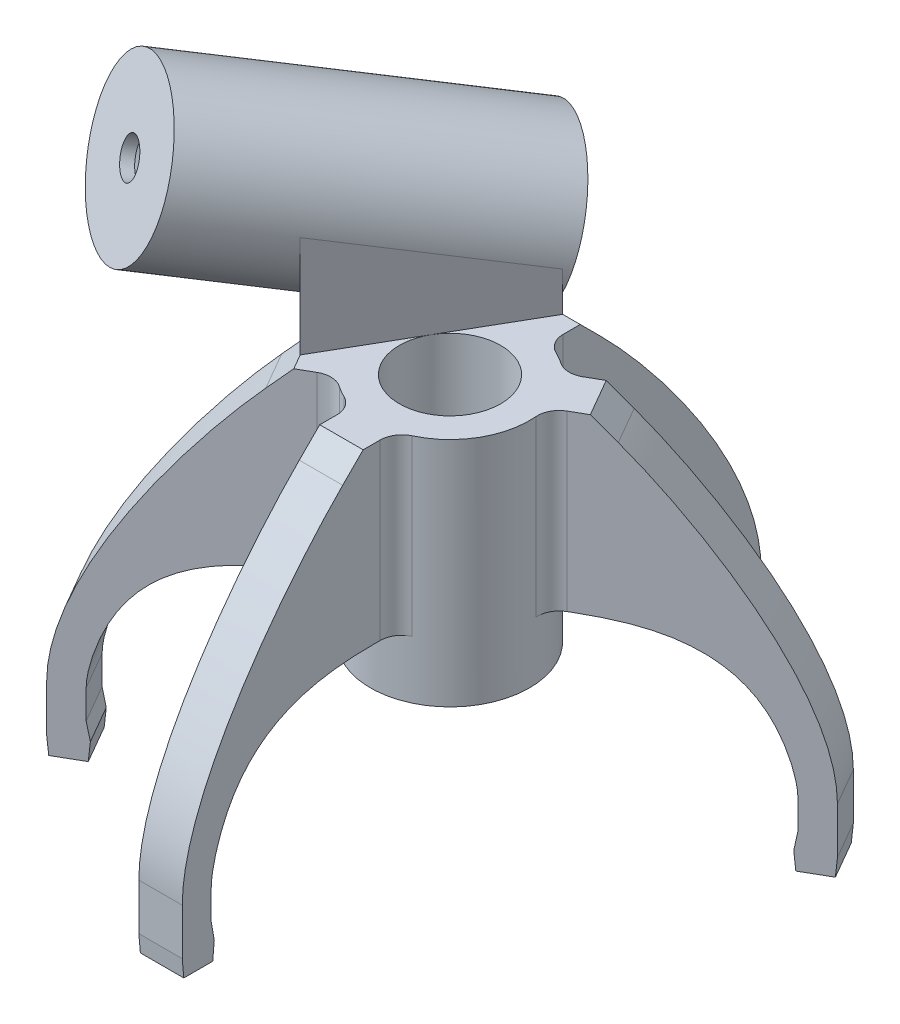
from build123d import *

# Parameters (mm, degrees)
SKETCH1_R                = 5.5
SKETCH1_R_2              = 1.25
BOSS_EXTRUDE1_DEPTH      = 16
BOSS_EXTRUDE2_DEPTH      = 1.5
BOSS_EXTRUDE3_DEPTH      = 3
CIRPATTERN1_COUNT        = 5
CIRPATTERN1_ANGLE        = 240
FILLET1_R                = 1.5
SKETCH6_R                = 3.5
CUT_EXTRUDE1_DEPTH       = 15.2
SKETCH10_R               = 5.5
SKETCH10_R_2             = 1.25
BOSS_EXTRUDE4_DEPTH      = 16
BOSS_EXTRUDE4_DEPTH_BACK = 6
BOSS_EXTRUDE10_REACH     = 16.574
SKETCH11_R               = 3.5
CUT_EXTRUDE2_DEPTH       = 21.2


with BuildPart() as part:
    # Sketch1 → Boss-Extrude1 (new body)
    with BuildSketch(Plane(origin=(0, 0, 0), x_dir=(1, 0, 0), z_dir=(0, 1, 0))):
        Circle(SKETCH1_R)
        Circle(SKETCH1_R_2, mode=Mode.SUBTRACT)
    extrude(amount=BOSS_EXTRUDE1_DEPTH)

    # Sketch2 → Boss-Extrude2 (add, symmetric)
    with BuildSketch(Plane(origin=(0, 0, 0), x_dir=(0, 0, -1), z_dir=(1, 0, 0))):
        with BuildLine():
            Line((18, -5), (20, -5))
            add(Edge.make_bspline(
                [(8.914213562, 14.585786438), (13.074333826, 10.425666174), (20, 1.461761402), (20, -5)],
                knots=[0.14734609, 0.14734609, 0.14734609, 0.14734609, 1, 1, 1, 1], degree=3))
            Line((8.914213562, 14.585786438), (7.5, 16))
            Line((7.5, 16), (5.5, 16))
            Line((5.5, 16), (1.25, 16))
            Line((1.25, 16), (1.25, 4))
            Line((1.25, 4), (6.70571865, 4))
            add(Edge.make_bspline(
                [(6.70571865, 4), (10.522194615, 4), (16.021169224, 3.257262603), (18, -4.005650027), (18, -5)],
                knots=[0, 0, 0, 0, 0.785490543, 1, 1, 1, 1], degree=3))
        make_face()
    boss_extrude2 = extrude(amount=BOSS_EXTRUDE2_DEPTH, both=True)

    # Sketch8 → Boss-Extrude3 (add)
    with BuildSketch(Plane(origin=(1.5, 0, 0), x_dir=(0, 0, -1), z_dir=(1, 0, 0))):
        Polygon((18, -7), (17.788407623, -8.2), (17.894203812, -9.409255967), (19.894203812, -9.409255967), (20, -8.2), (20, -7), (20, -5), (18, -5), align=None)
    boss_extrude3 = extrude(amount=-BOSS_EXTRUDE3_DEPTH)

    # CirPattern1: Boss-Extrude2, Boss-Extrude3 ×5 about axis
    cirpattern1_axis = Axis((0, 16, 0), (0, -1, 0))
    for i in range(1, CIRPATTERN1_COUNT):
        add(boss_extrude2.rotate(cirpattern1_axis, i * CIRPATTERN1_ANGLE / (CIRPATTERN1_COUNT - 1)))
        add(boss_extrude3.rotate(cirpattern1_axis, i * CIRPATTERN1_ANGLE / (CIRPATTERN1_COUNT - 1)))

    # Fillet1
    fillet1_edges = [part.edges().sort_by_distance(p)[0] for p in [
        (-5.332575695, 10, 1.346713205),
        (1.5, 10, -5.291502622),
        (-1.5, 10, -5.291502622),
        (3.832575695, 10, -3.944789417),
        (5.332575695, 10, 1.346713205),
        (1.5, 10, 5.291502622),
        (-3.832575695, 10, 3.944789417),
        (5.332575695, 10, -1.346713205),
        (3.832575695, 10, 3.944789417),
        (-1.5, 10, 5.291502622),
    ]]
    fillet(fillet1_edges, radius=FILLET1_R)

    # Sketch6 → Cut-Extrude1 (cut)
    with BuildSketch(Plane(origin=(0, 16, 0), x_dir=(1, 0, 0), z_dir=(0, 1, 0))):
        Circle(SKETCH6_R)
    extrude(amount=-CUT_EXTRUDE1_DEPTH, mode=Mode.SUBTRACT)

    # Sketch10 → Boss-Extrude4 (add, two sides)
    with BuildSketch(Plane(origin=(-2.351141009, 1.527864045, 4.072295684), x_dir=(0.866025404, 0, 0.5), z_dir=(-0.475528258, 0.309016994, 0.823639104))) as boss_extrude4_sk:
        with Locations((9, 19.842637557)):
            Circle(SKETCH10_R)
        with Locations((9, 19.842637557)):
            Circle(SKETCH10_R_2, mode=Mode.SUBTRACT)
    extrude(amount=BOSS_EXTRUDE4_DEPTH)
    extrude(boss_extrude4_sk.sketch, amount=-BOSS_EXTRUDE4_DEPTH_BACK)

    # Sketch16 → Boss-Extrude10 (add, up to next)
    with BuildSketch(Plane(origin=(0, 16, 0), x_dir=(1, 0, 0), z_dir=(0, 1, 0)), mode=Mode.PRIVATE) as boss_extrude10_sk1:
        with BuildLine():
            Line((6.350852961, 4), (-0.288675135, -7.5))
            Line((-0.288675135, -7.5), (1.5, -7.5))
            Line((1.5, -7.5), (1.5, -6.32455532))
            ThreePointArc((1.5, -6.32455532), (1.732268618, -5.522771595), (2.357142857, -4.969293466))
            ThreePointArc((2.357142857, -4.969293466), (2.75, -4.763139721), (3.124962952, -4.525992328))
            ThreePointArc((3.124962952, -4.525992328), (3.305889272, -4.418971164), (3.5, -4.338293482))
            ThreePointArc((3.5, -4.338293482), (4.126842059, -4.267834221), (4.727225575, -4.461315766))
            Line((4.727225575, -4.461315766), (5.23810468, -4.756271954))
            add(Edge.make_bspline(
                [(5.522613217, -0.930402058), (5.049152923, -3.22167428), (5.23810468, -4.756271954)],
                knots=[5.532424046, 5.532424046, 5.532424046, 5.894267037, 5.894267037, 5.894267037], degree=2, weights=[1, 0.9836783, 1]))
            ThreePointArc((5.522613217, -0.930402058), (5.482385541, -0.688512638), (5.482105809, -0.443301138))
            ThreePointArc((5.482105809, -0.443301138), (5.5, 0), (5.482105809, 0.443301138))
            ThreePointArc((5.482105809, 0.443301138), (5.648994809, 1.261197168), (6.227225575, 1.863239554))
            Line((6.227225575, 1.863239554), (6.278306217, 1.892730977))
            add(Edge.make_bspline(
                [(6.759951788, 3.291420046), (6.498738058, 2.578407465), (6.278306217, 1.892730977)],
                knots=[5.225610557, 5.225610557, 5.225610557, 5.322030654, 5.322030654, 5.322030654], degree=2, weights=[1, 0.998838121, 1]))
            Line((6.759951788, 3.291420046), (6.350852961, 4))
        make_face()
    boss_extrude10_tool1 = extrude(boss_extrude10_sk1.sketch, amount=BOSS_EXTRUDE10_REACH, mode=Mode.PRIVATE) - part.part
    add(boss_extrude10_tool1.solids().sort_by_distance((3.702235, 16, 2.406075))[0])

    # Sketch11 → Cut-Extrude2 (cut)
    with BuildSketch(Plane(origin=(0.50202854, -0.326237921, -0.869538938), x_dir=(-0.879643998, -0.156424143, -0.449174715), z_dir=(0.475528258, -0.309016994, -0.823639104))):
        with Locations((-12.14103215, 18.092142039)):
            Circle(SKETCH11_R)
    extrude(amount=-CUT_EXTRUDE2_DEPTH, mode=Mode.SUBTRACT)


with BuildPart() as body_2:
    # Mirror1: mirrored copy
    add(part.part.mirror(Plane(origin=(-25.980762114, 0, -15), x_dir=(-0.5, 0, 0.866025404), z_dir=(0.866025404, 0, 0.5))))


solid = body_2.part
